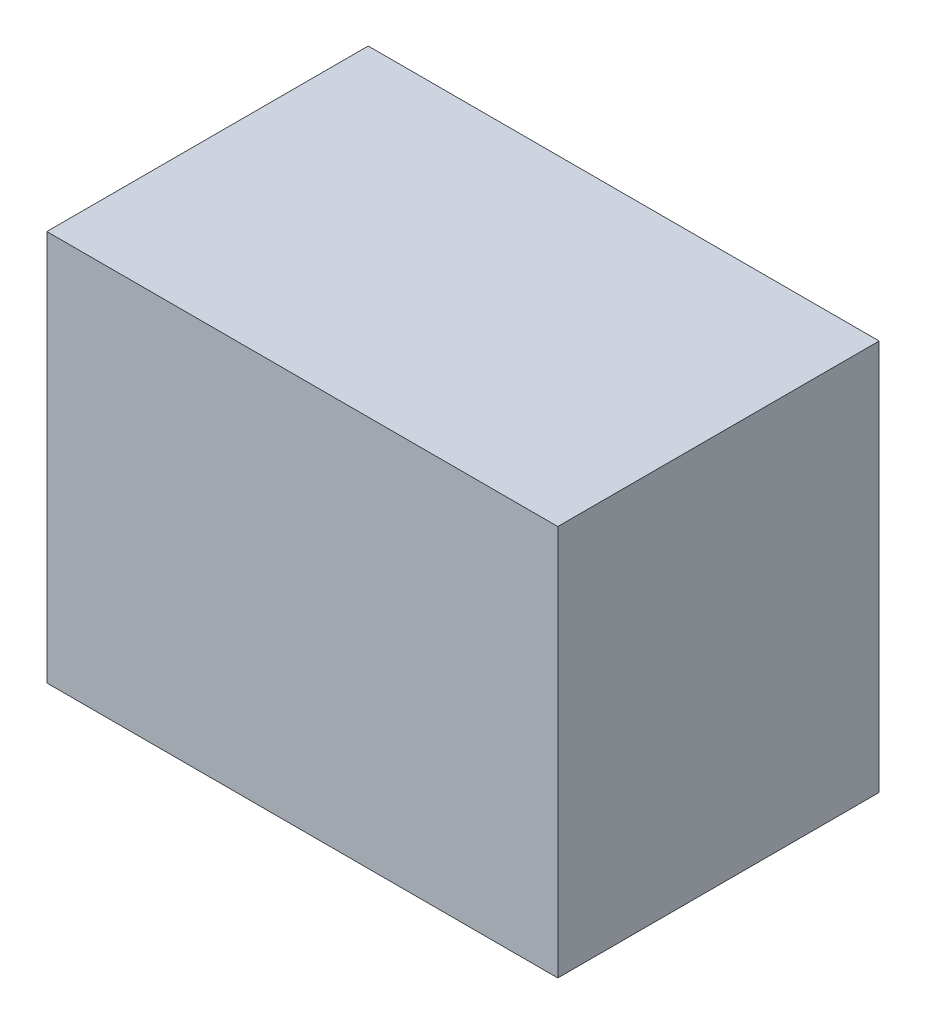
from build123d import *

# Parameters (mm, degrees)
POWERTHING_SKETCH_W      = 14.31
POWERTHING_SKETCH_H      = 9
POWERTHING_EXTRUDE_DEPTH = 10.95


with BuildPart() as part:
    # PowerThing Sketch → PowerThing Extrude (new body)
    with BuildSketch(Plane(origin=(0, 0, 0), x_dir=(1, 0, 0), z_dir=(0, 1, 0))):
        with Locations((7.155, 4.5)):
            Rectangle(POWERTHING_SKETCH_W, POWERTHING_SKETCH_H)
    extrude(amount=POWERTHING_EXTRUDE_DEPTH)


solid = part.part
